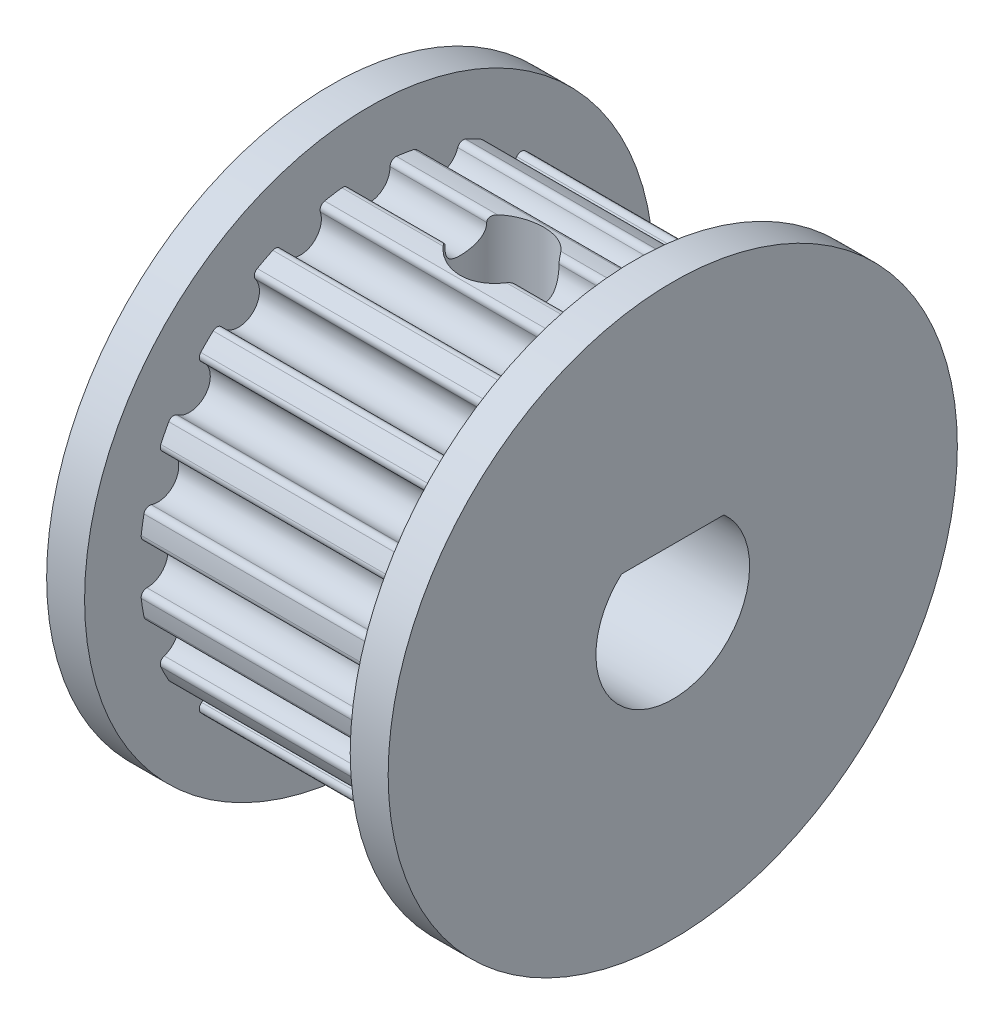
from build123d import *

# Parameters (mm, degrees)
SKETCH_3_R         = 0.55
F_20TOOTH_DEPTH    = 7
FILLET_1_R         = 0.15
CUT_EXTRUDE1_DEPTH = 10
SKETCH2_W          = 1.1
SKETCH2_H          = 5.990654115


with BuildPart() as part:
    # Эскиз1 → Body (revolve)
    with BuildSketch(Plane.XY):
        Polygon((1, 7.5), (0, 7.5), (0, 0), (9, 0), (9, 7.5), (8, 7.5), (8, 6.05), (1, 6.05), align=None)
    revolve(axis=Axis((0, 0, 0), (1, 0, 0)))

    # Эскиз3 → 20tooth (cut)
    with BuildSketch(Plane(origin=(1, 0, 0), x_dir=(0, 0, -1), z_dir=(1, 0, 0))):
        with Locations((5.568435903, -1.809294502)):
            Circle(SKETCH_3_R)
        with Locations((4.736794502, -3.441482652)):
            Circle(SKETCH_3_R)
        with Locations((3.441482652, -4.736794502)):
            Circle(SKETCH_3_R)
        with Locations((1.809294502, -5.568435903)):
            Circle(SKETCH_3_R)
        with Locations((0, -5.855)):
            Circle(SKETCH_3_R)
        with Locations((5.855, 0)):
            Circle(SKETCH_3_R)
        with Locations((-1.809294502, -5.568435903)):
            Circle(SKETCH_3_R)
        with Locations((-3.441482652, -4.736794502)):
            Circle(SKETCH_3_R)
        with Locations((-4.736794502, -3.441482652)):
            Circle(SKETCH_3_R)
        with Locations((-5.568435903, -1.809294502)):
            Circle(SKETCH_3_R)
        with Locations((-5.855, 0)):
            Circle(SKETCH_3_R)
        with Locations((-5.568435903, 1.809294502)):
            Circle(SKETCH_3_R)
        with Locations((-4.736794502, 3.441482652)):
            Circle(SKETCH_3_R)
        with Locations((-3.441482652, 4.736794502)):
            Circle(SKETCH_3_R)
        with Locations((-1.809294502, 5.568435903)):
            Circle(SKETCH_3_R)
        with Locations((0, 5.855)):
            Circle(SKETCH_3_R)
        with Locations((1.809294502, 5.568435903)):
            Circle(SKETCH_3_R)
        with Locations((3.441482652, 4.736794502)):
            Circle(SKETCH_3_R)
        with Locations((4.736794502, 3.441482652)):
            Circle(SKETCH_3_R)
        with Locations((5.568435903, 1.809294502)):
            Circle(SKETCH_3_R)
    extrude(amount=F_20TOOTH_DEPTH, mode=Mode.SUBTRACT)

    # Скругление1
    fillet_1_edges = [part.edges().sort_by_distance(p)[0] for p in [
        (4.5, -1.365858655, 5.893804386),
        (4.5, -2.359288434, 5.571019483),
        (4.5, 0.522276943, 6.027414603),
        (4.5, -0.522276943, 6.027414603),
        (4.5, 2.359288434, 5.571019483),
        (4.5, 1.365858655, 5.893804386),
        (4.5, 3.965356335, 4.569294161),
        (4.5, 3.120294491, 5.18326753),
        (4.5, 5.18326753, 3.120294491),
        (4.5, 4.569294161, 3.965356335),
        (4.5, 5.893804386, 1.365858655),
        (4.5, 5.571019483, 2.359288434),
        (4.5, 6.027414603, -0.522276943),
        (4.5, 6.027414603, 0.522276943),
        (4.5, 5.571019483, -2.359288434),
        (4.5, 5.893804386, -1.365858655),
        (4.5, 4.569294161, -3.965356335),
        (4.5, 5.18326753, -3.120294491),
        (4.5, 3.120294491, -5.18326753),
        (4.5, 3.965356335, -4.569294161),
        (4.5, 1.365858655, -5.893804386),
        (4.5, 2.359288434, -5.571019483),
        (4.5, -2.359288434, -5.571019483),
        (4.5, -1.365858655, -5.893804386),
        (4.5, -3.965356335, -4.569294161),
        (4.5, -3.120294491, -5.18326753),
        (4.5, -5.18326753, -3.120294491),
        (4.5, -4.569294161, -3.965356335),
        (4.5, -5.893804386, -1.365858655),
        (4.5, -5.571019483, -2.359288434),
        (4.5, -6.027414603, 0.522276943),
        (4.5, -6.027414603, -0.522276943),
        (4.5, -0.522276943, -6.027414603),
        (4.5, 0.522276943, -6.027414603),
        (4.5, -5.571019483, 2.359288434),
        (4.5, -5.893804386, 1.365858655),
        (4.5, -4.569294161, 3.965356335),
        (4.5, -5.18326753, 3.120294491),
        (4.5, -3.120294491, 5.18326753),
        (4.5, -3.965356335, 4.569294161),
    ]]
    fillet(fillet_1_edges, radius=FILLET_1_R)

    # Sketch1 → Cut-Extrude1 (cut, through all)
    with BuildSketch(Plane(origin=(9, 0, 0), x_dir=(0, 0, -1), z_dir=(1, 0, 0))):
        with BuildLine():
            Line((-1.35, 1.509345885), (1.35, 1.509345885))
            ThreePointArc((1.35, 1.509345885), (0, -2.025), (-1.35, 1.509345885))
        make_face()
    extrude(amount=-CUT_EXTRUDE1_DEPTH, mode=Mode.SUBTRACT)

    # Sketch2 → M2 Clearance Hole1 (revolve, cut)
    with BuildSketch(Plane(origin=(4.5, 1.509345885, 0), x_dir=(0, 0, -1), z_dir=(1, 0, 0))):
        with Locations((0.55, 2.995327058)):
            Rectangle(SKETCH2_W, SKETCH2_H)
    revolve(axis=Axis((4.5, -4.840654115, 0), (0, 1, 0)), mode=Mode.SUBTRACT)


solid = part.part
